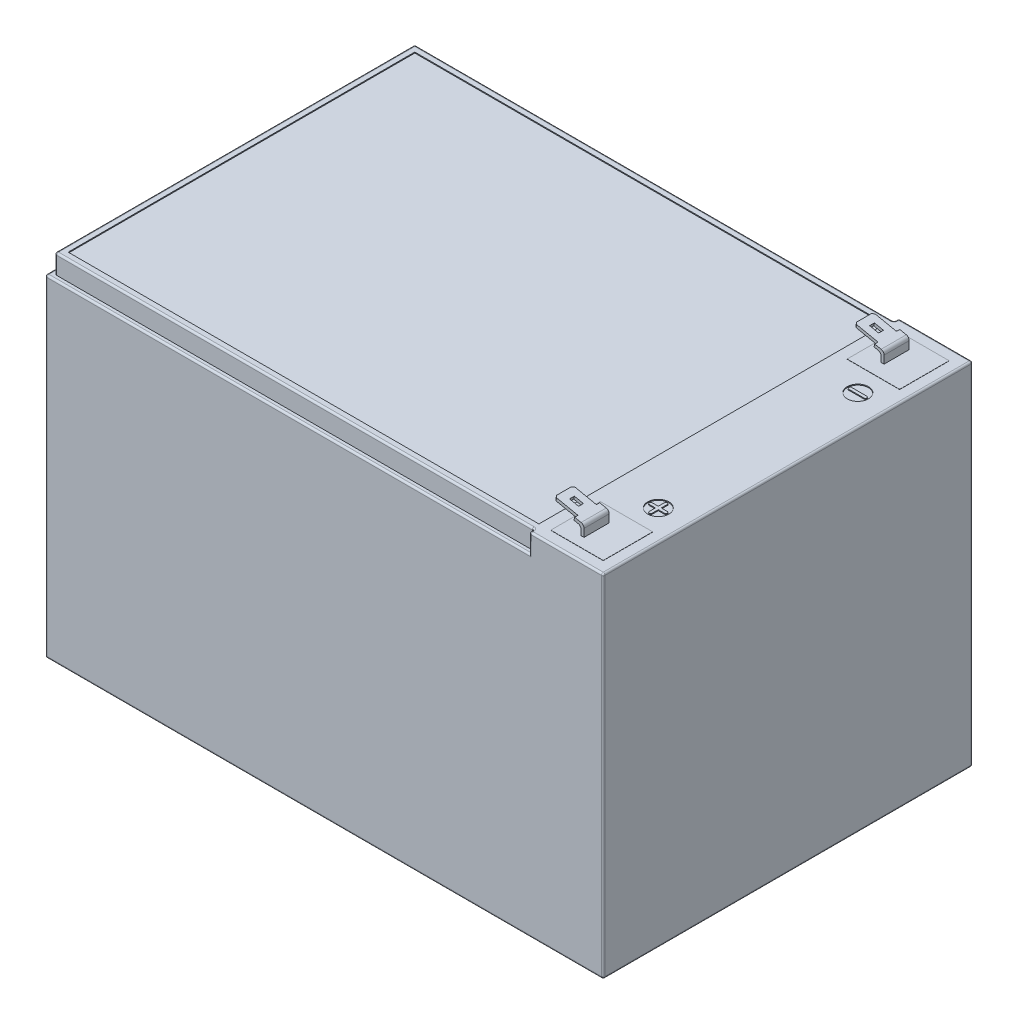
from build123d import *

# Parameters (mm, degrees)
SKETCH1_W                = 151
SKETCH1_H                = 100
BOSS_EXTRUDE1_DEPTH      = 95
BOSS_EXTRUDE2_DEPTH      = 6.8
SKETCH4_W                = 6.4
SKETCH4_H                = 0.9
SKETCH4_W_2              = 2.5
SKETCH4_H_2              = 1.3
CUT_EXTRUDE1_DEPTH       = 0.8
CHAMFER1_SIZE            = 0.5
FILLET1_R                = 1
CHAMFER1_OF_MIRROR1_SIZE = 0.5
FILLET1_OF_MIRROR1_R     = 1
CUT_EXTRUDE2_DEPTH       = 5.2
FILLET2_R                = 0.5
SKETCH6_R                = 2.875
SKETCH6_W                = 127.4
SKETCH6_H                = 93.8
SKETCH6_W_2              = 14.2
SKETCH6_H_2              = 13.4
CUT_EXTRUDE3_DEPTH       = 0.25
SKETCH7_W                = 14.2
SKETCH7_H                = 13.4
BOSS_EXTRUDE3_DEPTH      = 0.3
SKETCH8_W                = 14.2
SKETCH8_H                = 13.4
BOSS_EXTRUDE4_DEPTH      = 0.3
BOSS_EXTRUDE5_DEPTH      = 0.5
MIRROR3_COPY_1_DEPTH     = 0.5


with BuildPart() as part:
    # Sketch1 → Boss-Extrude1 (new body)
    with BuildSketch(Plane(origin=(0, 0, 0), x_dir=(1, 0, 0), z_dir=(0, 1, 0))):
        with Locations((0.44359577, -6.438895417)):
            Rectangle(SKETCH1_W, SKETCH1_H)
    extrude(amount=BOSS_EXTRUDE1_DEPTH)

    # Sketch2 → Boss-Extrude2 (add)
    with BuildSketch(Plane.XY.offset(50.438895417)):
        Polygon((63.94359577, 95), (63.94359577, 97.325729645), (55.769774606, 99.029953582), (55.933061472, 99.813112186), (64.74359577, 97.976134945), (64.74359577, 95), align=None)
    boss_extrude2 = extrude(amount=-BOSS_EXTRUDE2_DEPTH)

    # Sketch4 → Cut-Extrude1 (cut)
    with BuildSketch(Plane(origin=(22.274020552, 106.830949022, 0), x_dir=(0.978948255, -0.204108582, 0), z_dir=(0.204108582, 0.978948255, 0))):
        with Locations((37.582860112, -44.088895417)):
            Rectangle(SKETCH4_W, SKETCH4_H)
        with Locations((37.582860112, -49.988895417)):
            Rectangle(SKETCH4_W, SKETCH4_H)
        with Locations((37.832860112, -47.038895417)):
            Rectangle(SKETCH4_W_2, SKETCH4_H_2)
    cut_extrude1 = extrude(amount=-CUT_EXTRUDE1_DEPTH, mode=Mode.SUBTRACT)

    # Chamfer1
    chamfer1_edges = [part.edges().sort_by_distance(p)[0] for p in [
        (55.851418039, 99.421532884, 44.538895417),
        (55.851418039, 99.421532884, 49.538895417),
    ]]
    chamfer(chamfer1_edges, length=CHAMFER1_SIZE)

    # Fillet1
    fillet1_edges = [part.edges().sort_by_distance(p)[0] for p in [
        (63.94359577, 97.325729645, 47.038895417),
        (64.74359577, 97.976134945, 47.038895417),
    ]]
    fillet(fillet1_edges, radius=FILLET1_R)

    # Mirror1: Boss-Extrude2, Cut-Extrude1 across plane
    add(boss_extrude2.mirror(Plane.XY.offset(6.438895417)))
    add(cut_extrude1.mirror(Plane.XY.offset(6.438895417)), mode=Mode.SUBTRACT)

    # Chamfer1 of Mirror1
    chamfer1_of_mirror1_edges = [part.edges().sort_by_distance(p)[0] for p in [
        (55.851418039, 99.421532884, -31.661104583),
        (55.851418039, 99.421532884, -36.661104583),
    ]]
    chamfer(chamfer1_of_mirror1_edges, length=CHAMFER1_OF_MIRROR1_SIZE)

    # Fillet1 of Mirror1
    fillet1_of_mirror1_edges = [part.edges().sort_by_distance(p)[0] for p in [
        (63.94359577, 97.325729645, -34.161104583),
        (64.74359577, 97.976134945, -34.161104583),
    ]]
    fillet(fillet1_of_mirror1_edges, radius=FILLET1_OF_MIRROR1_R)

    # Sketch5 → Cut-Extrude2 (cut)
    with BuildSketch(Plane(origin=(0, 95, 0), x_dir=(1, 0, 0), z_dir=(0, 1, 0))):
        Polygon((55.94359577, -56.438895417), (55.94359577, -55.138895417), (-73.75640423, -55.138895417), (-73.75640423, 42.261104583), (55.94359577, 42.261104583), (55.94359577, 43.561104583), (-75.05640423, 43.561104583), (-75.05640423, -56.438895417), align=None)
    extrude(amount=-CUT_EXTRUDE2_DEPTH, mode=Mode.SUBTRACT)

    # Fillet2
    fillet2_edges = [part.edges().sort_by_distance(p)[0] for p in [
        (75.94359577, 95, 6.438895417),
        (65.94359577, 95, -43.561104583),
        (65.94359577, 95, 56.438895417),
        (-75.05640423, 44.9, -43.561104583),
        (-75.05640423, 44.9, 56.438895417),
        (-9.55640423, 89.8, 56.438895417),
        (55.94359577, 92.4, 56.438895417),
        (-75.05640423, 89.8, 6.438895417),
        (-9.55640423, 89.8, -43.561104583),
        (55.94359577, 92.4, -43.561104583),
        (55.94359577, 92.4, -42.261104583),
        (-73.75640423, 92.4, -42.261104583),
        (-73.75640423, 92.4, 55.138895417),
        (55.94359577, 92.4, 55.138895417),
        (55.94359577, 95, 55.788895417),
        (-8.90640423, 95, 55.138895417),
        (-73.75640423, 95, 6.438895417),
        (-8.90640423, 95, -42.261104583),
        (55.94359577, 95, -42.911104583),
        (0.44359577, 0, -43.561104583),
        (75.94359577, 0, 6.438895417),
        (0.44359577, 0, 56.438895417),
        (-75.05640423, 0, 6.438895417),
        (75.94359577, 47.5, -43.561104583),
        (75.94359577, 47.5, 56.438895417),
    ]]
    fillet(fillet2_edges, radius=FILLET2_R)

    # Sketch6 → Cut-Extrude3 (cut)
    with BuildSketch(Plane(origin=(0, 95, 0), x_dir=(1, 0, 0), z_dir=(0, 1, 0))):
        with Locations((67.84359577, 20.561104583)):
            Circle(SKETCH6_R)
        with BuildLine():
            Line((65.69359577, 20.961104583), (69.99359577, 20.961104583))
            ThreePointArc((69.99359577, 20.961104583), (70.170372465, 20.887881278), (70.24359577, 20.711104583))
            Line((70.24359577, 20.711104583), (70.24359577, 20.411104583))
            ThreePointArc((70.24359577, 20.411104583), (70.170372465, 20.234327888), (69.99359577, 20.161104583))
            Line((69.99359577, 20.161104583), (65.69359577, 20.161104583))
            ThreePointArc((65.69359577, 20.161104583), (65.516819074, 20.234327888), (65.44359577, 20.411104583))
            Line((65.44359577, 20.411104583), (65.44359577, 20.711104583))
            ThreePointArc((65.44359577, 20.711104583), (65.516819074, 20.887881278), (65.69359577, 20.961104583))
        make_face(mode=Mode.SUBTRACT)
        with Locations((67.84359577, -33.438895417)):
            Circle(SKETCH6_R)
        with BuildLine():
            Line((67.44359577, -31.288895417), (67.44359577, -33.038895417))
            Line((67.44359577, -33.038895417), (65.69359577, -33.038895417))
            ThreePointArc((65.69359577, -33.038895417), (65.516819074, -33.112118722), (65.44359577, -33.288895417))
            Line((65.44359577, -33.288895417), (65.44359577, -33.588895417))
            ThreePointArc((65.44359577, -33.588895417), (65.516819074, -33.765672112), (65.69359577, -33.838895417))
            Line((65.69359577, -33.838895417), (67.44359577, -33.838895417))
            Line((67.44359577, -33.838895417), (67.44359577, -35.588895417))
            ThreePointArc((67.44359577, -35.588895417), (67.516819074, -35.765672112), (67.69359577, -35.838895417))
            Line((67.69359577, -35.838895417), (67.99359577, -35.838895417))
            ThreePointArc((67.99359577, -35.838895417), (68.170372465, -35.765672112), (68.24359577, -35.588895417))
            Line((68.24359577, -35.588895417), (68.24359577, -33.838895417))
            Line((68.24359577, -33.838895417), (69.99359577, -33.838895417))
            ThreePointArc((69.99359577, -33.838895417), (70.170372465, -33.765672112), (70.24359577, -33.588895417))
            Line((70.24359577, -33.588895417), (70.24359577, -33.288895417))
            ThreePointArc((70.24359577, -33.288895417), (70.170372465, -33.112118722), (69.99359577, -33.038895417))
            Line((69.99359577, -33.038895417), (68.24359577, -33.038895417))
            Line((68.24359577, -33.038895417), (68.24359577, -31.288895417))
            ThreePointArc((68.24359577, -31.288895417), (68.170372465, -31.112118722), (67.99359577, -31.038895417))
            Line((67.99359577, -31.038895417), (67.69359577, -31.038895417))
            ThreePointArc((67.69359577, -31.038895417), (67.516819074, -31.112118722), (67.44359577, -31.288895417))
        make_face(mode=Mode.SUBTRACT)
        with Locations((-8.25640423, -6.438895417)):
            Rectangle(SKETCH6_W, SKETCH6_H)
        with Locations((65.64359577, 33.661104583)):
            Rectangle(SKETCH6_W_2, SKETCH6_H_2)
        with Locations((65.64359577, -46.538895417)):
            Rectangle(SKETCH6_W_2, SKETCH6_H_2)
    extrude(amount=-CUT_EXTRUDE3_DEPTH, mode=Mode.SUBTRACT)

    # Sketch7 → Boss-Extrude3 (add)
    with BuildSketch(Plane(origin=(0, 94.75, 0), x_dir=(1, 0, 0), z_dir=(0, 1, 0))):
        with Locations((65.64359577, 33.661104583)):
            Rectangle(SKETCH7_W, SKETCH7_H)
    extrude(amount=BOSS_EXTRUDE3_DEPTH)

    # Sketch8 → Boss-Extrude4 (add)
    with BuildSketch(Plane(origin=(0, 94.75, 0), x_dir=(1, 0, 0), z_dir=(0, 1, 0))):
        with Locations((65.64359577, -46.538895417)):
            Rectangle(SKETCH8_W, SKETCH8_H)
    extrude(amount=BOSS_EXTRUDE4_DEPTH)

    # Sketch9 → Boss-Extrude5 (add)
    with BuildSketch(Plane.XZ):
        with BuildLine():
            Line((-70.05640423, 43.738895417), (-70.05640423, 50.938895417))
            ThreePointArc((-70.05640423, 50.938895417), (-69.909957621, 51.292448808), (-69.55640423, 51.438895417))
            Line((-69.55640423, 51.438895417), (-62.35640423, 51.438895417))
            ThreePointArc((-62.35640423, 51.438895417), (-62.00285084, 51.292448808), (-61.85640423, 50.938895417))
            Line((-61.85640423, 50.938895417), (-61.85640423, 49.938895417))
            ThreePointArc((-61.85640423, 49.938895417), (-62.00285084, 49.585342027), (-62.35640423, 49.438895417))
            Line((-62.35640423, 49.438895417), (-68.05640423, 49.438895417))
            Line((-68.05640423, 49.438895417), (-68.05640423, 43.738895417))
            ThreePointArc((-68.05640423, 43.738895417), (-68.20285084, 43.385342027), (-68.55640423, 43.238895417))
            Line((-68.55640423, 43.238895417), (-69.55640423, 43.238895417))
            ThreePointArc((-69.55640423, 43.238895417), (-69.909957621, 43.385342027), (-70.05640423, 43.738895417))
        make_face()
    boss_extrude5 = extrude(amount=BOSS_EXTRUDE5_DEPTH)

    # Mirror2: Boss-Extrude5 across plane
    add(boss_extrude5.mirror(Plane.ZY.offset(-0.44359577)))

    # Mirror3: Boss-Extrude5 across plane
    add(boss_extrude5.mirror(Plane.XY.offset(6.438895417)))

    # Mirror3 copy 1 sketch → Mirror3 copy 1 (add)
    with BuildSketch(Plane(origin=(0.887191539, 0, 12.877790834), x_dir=(-1, 0, 0), z_dir=(0, -1, 0))):
        with BuildLine():
            Line((-70.05640423, 43.738895417), (-70.05640423, 50.938895417))
            ThreePointArc((-70.05640423, 50.938895417), (-69.909957621, 51.292448808), (-69.55640423, 51.438895417))
            Line((-69.55640423, 51.438895417), (-62.35640423, 51.438895417))
            ThreePointArc((-62.35640423, 51.438895417), (-62.00285084, 51.292448808), (-61.85640423, 50.938895417))
            Line((-61.85640423, 50.938895417), (-61.85640423, 49.938895417))
            ThreePointArc((-61.85640423, 49.938895417), (-62.00285084, 49.585342027), (-62.35640423, 49.438895417))
            Line((-62.35640423, 49.438895417), (-68.05640423, 49.438895417))
            Line((-68.05640423, 49.438895417), (-68.05640423, 43.738895417))
            ThreePointArc((-68.05640423, 43.738895417), (-68.20285084, 43.385342027), (-68.55640423, 43.238895417))
            Line((-68.55640423, 43.238895417), (-69.55640423, 43.238895417))
            ThreePointArc((-69.55640423, 43.238895417), (-69.909957621, 43.385342027), (-70.05640423, 43.738895417))
        make_face()
    extrude(amount=MIRROR3_COPY_1_DEPTH)


solid = part.part
